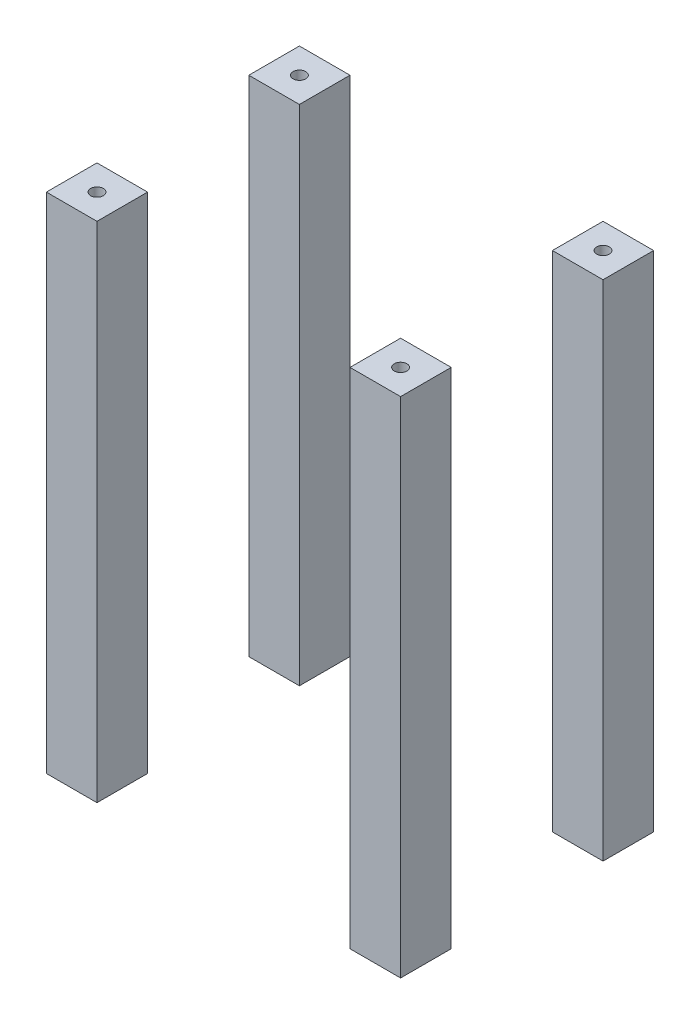
from build123d import *

# Parameters (mm, degrees)
SKIZZE3_W                         = 20
SKIZZE3_H                         = 20
SKIZZE3_R                         = 2.5
AUFSATZ_LINEAR_AUSTRAGEN1_DEPTH   = 199
AUFSATZ_LINEAR_AUSTRAGEN1_2_DEPTH = 199
AUFSATZ_LINEAR_AUSTRAGEN1_3_DEPTH = 199
AUFSATZ_LINEAR_AUSTRAGEN1_4_DEPTH = 199


with BuildPart() as part:
    # Skizze3 → Aufsatz-Linear austragen1 (new body)
    with BuildSketch(Plane(origin=(0, 0, 0), x_dir=(1, 0, 0), z_dir=(0, 1, 0))):
        with Locations((-60, -42.65)):
            Rectangle(SKIZZE3_W, SKIZZE3_H)
        with Locations((-60, -42.65)):
            Circle(SKIZZE3_R, mode=Mode.SUBTRACT)
    extrude(amount=AUFSATZ_LINEAR_AUSTRAGEN1_DEPTH)


with BuildPart() as body_2:
    # Skizze3 → Aufsatz-Linear austragen1 2 (new body)
    with BuildSketch(Plane(origin=(0, 0, 0), x_dir=(1, 0, 0), z_dir=(0, 1, 0))):
        with Locations((60, -42.65)):
            Rectangle(SKIZZE3_W, SKIZZE3_H)
        with Locations((60, -42.65)):
            Circle(SKIZZE3_R, mode=Mode.SUBTRACT)
    extrude(amount=AUFSATZ_LINEAR_AUSTRAGEN1_2_DEPTH)


with BuildPart() as body_3:
    # Skizze3 → Aufsatz-Linear austragen1 3 (new body)
    with BuildSketch(Plane(origin=(0, 0, 0), x_dir=(1, 0, 0), z_dir=(0, 1, 0))):
        with Locations((60, -122.65)):
            Rectangle(SKIZZE3_W, SKIZZE3_H)
        with Locations((60, -122.65)):
            Circle(SKIZZE3_R, mode=Mode.SUBTRACT)
    extrude(amount=AUFSATZ_LINEAR_AUSTRAGEN1_3_DEPTH)


with BuildPart() as body_4:
    # Skizze3 → Aufsatz-Linear austragen1 4 (new body)
    with BuildSketch(Plane(origin=(0, 0, 0), x_dir=(1, 0, 0), z_dir=(0, 1, 0))):
        with Locations((-60, -122.65)):
            Rectangle(SKIZZE3_W, SKIZZE3_H)
        with Locations((-60, -122.65)):
            Circle(SKIZZE3_R, mode=Mode.SUBTRACT)
    extrude(amount=AUFSATZ_LINEAR_AUSTRAGEN1_4_DEPTH)


solid = Compound([part.part, body_2.part, body_3.part, body_4.part])
